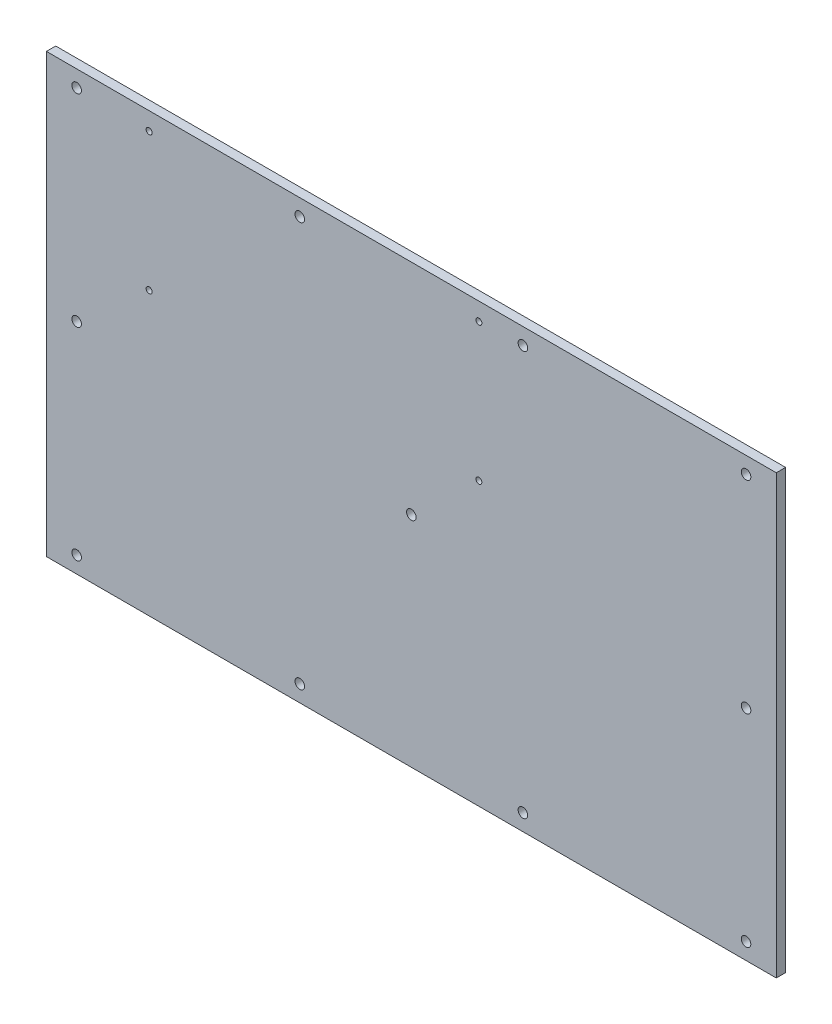
from build123d import *

# Parameters (mm, degrees)
SKETCH1_W                 = 248.92
SKETCH1_H                 = 149.225
BOSS_EXTRUDE1_DEPTH       = 3.175
F_4_CLEARANCE_HOLE1_D     = 3.2639
F_4_CLEARANCE_HOLE1_DEPTH = 56.388
F_4_CLEARANCE_HOLE1_TIP   = 0.980574487
F_4_40_TAPPED_HOLE1_D     = 2.032
F_4_40_TAPPED_HOLE1_DEPTH = 7.62
F_4_40_TAPPED_HOLE1_TIP   = 0.610474389


with BuildPart() as part:
    # Sketch1 → Boss-Extrude1 (new body)
    with BuildSketch(Plane.XY):
        Rectangle(SKETCH1_W, SKETCH1_H)
    extrude(amount=BOSS_EXTRUDE1_DEPTH)

    # #4 Clearance Hole1
    with Locations(Plane(origin=(0, 0, 0), x_dir=(-1, 0, 0), z_dir=(0, 0, -1))):
        with Locations((114.1476, -68.9864), (-114.1476, -68.9864), (-114.1476, 68.9864), (114.1476, 68.9864), (114.1476, 0), (-114.1476, 0), (38.0492, 68.9864), (-38.0492, 68.9864), (-38.0492, -68.9864), (38.0492, -68.9864), (0, 0)):
            Hole(F_4_CLEARANCE_HOLE1_D / 2, depth=F_4_CLEARANCE_HOLE1_DEPTH)
            with Locations((0, 0, -(F_4_CLEARANCE_HOLE1_DEPTH + F_4_CLEARANCE_HOLE1_TIP / 2))):  # 118° drill point
                Cone(0, F_4_CLEARANCE_HOLE1_D / 2, F_4_CLEARANCE_HOLE1_TIP, mode=Mode.SUBTRACT)

    # #4-40 Tapped Hole1
    with Locations(Plane(origin=(0, 0, 0), x_dir=(-1, 0, 0), z_dir=(0, 0, -1))):
        with Locations((-23.0378, 21.5773), (-23.0378, 68.5673), (89.4334, 68.5673), (89.4334, 21.5773)):
            Hole(F_4_40_TAPPED_HOLE1_D / 2, depth=F_4_40_TAPPED_HOLE1_DEPTH)
            with Locations((0, 0, -(F_4_40_TAPPED_HOLE1_DEPTH + F_4_40_TAPPED_HOLE1_TIP / 2))):  # 118° drill point
                Cone(0, F_4_40_TAPPED_HOLE1_D / 2, F_4_40_TAPPED_HOLE1_TIP, mode=Mode.SUBTRACT)


solid = part.part
